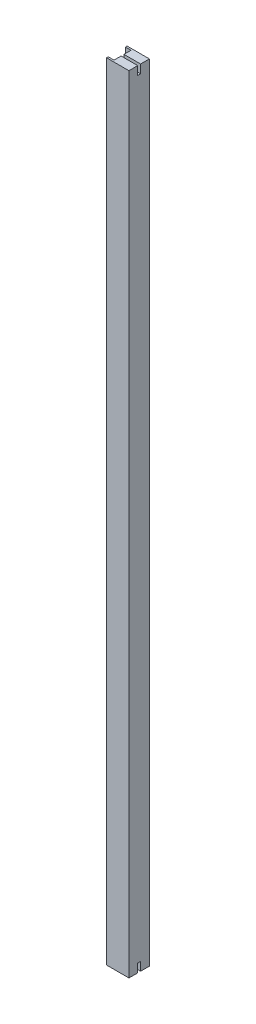
from build123d import *

# Parameters (mm, degrees)
EXTRUDE_1_DEPTH     = 1383.55
SKETCH_3_W          = 5
SKETCH_3_H          = 15
CUT_EXTRUDE_4_DEPTH = 40.25520667


with BuildPart() as part:
    # Эскиз1 → Бобышка-Вытянуть1 (new body)
    with BuildSketch(Plane(origin=(0, 0, 0), x_dir=(1, 0, 0), z_dir=(0, 1, 0))):
        Polygon((10, 2.5), (10, 15), (0, 15), (0, 18), (39.25520667, 18), (39.25520667, -18), (0, -18), (0, -15), (10, -15), (10, -2.5), (0, -2.5), (0, 2.5), align=None)
    extrude(amount=EXTRUDE_1_DEPTH)

    # Эскиз3 → Вырез-Вытянуть4 (cut, through all)
    with BuildSketch(Plane(origin=(39.25520667, 0, 0), x_dir=(0, 0, -1), z_dir=(1, 0, 0))):
        with Locations((0, 7.5)):
            Rectangle(SKETCH_3_W, SKETCH_3_H)
        with Locations((0, 1376.05)):
            Rectangle(SKETCH_3_W, SKETCH_3_H)
    extrude(amount=-CUT_EXTRUDE_4_DEPTH, mode=Mode.SUBTRACT)


solid = part.part
